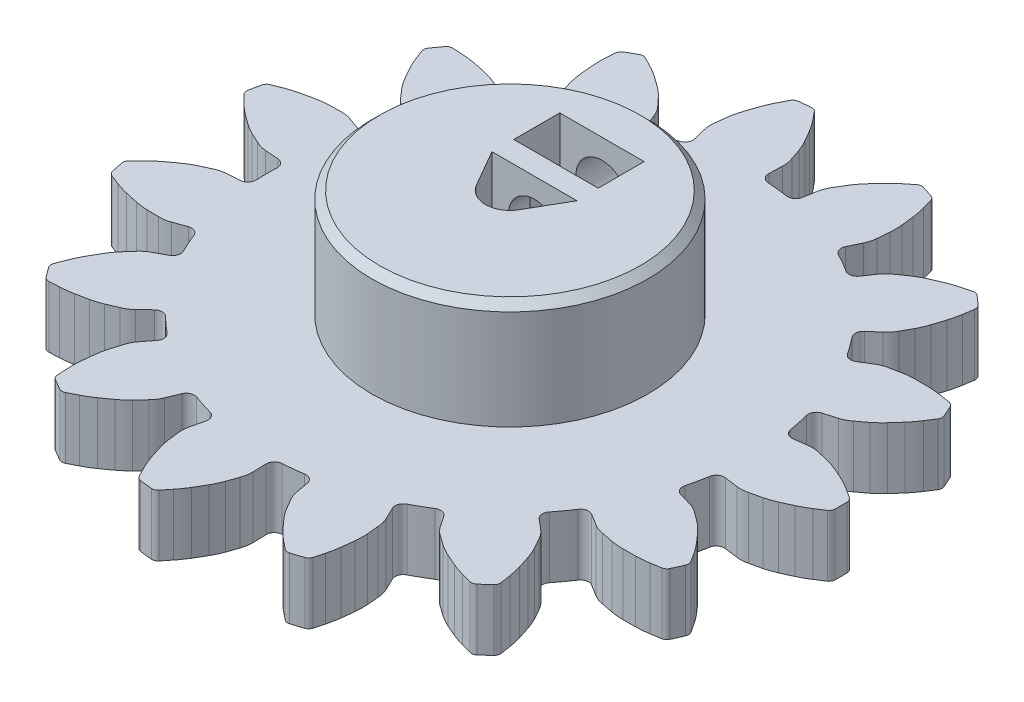
from build123d import *

# Parameters (mm, degrees)
BOSS_EXTRUDE1_DEPTH = 4
SKETCH2_R           = 9
BOSS_EXTRUDE2_DEPTH = 11
CUT_EXTRUDE1_DEPTH  = 12
SKETCH4_W           = 5.5
SKETCH4_H           = 3
CUT_EXTRUDE2_DEPTH  = 6
SKETCH5_R           = 1.7
CUT_EXTRUDE3_DEPTH  = 20.910692973
CHAMFER1_SIZE       = 0.5


with BuildPart() as part:
    # Sketch1 → Boss-Extrude1 (new body)
    with BuildSketch(Plane(origin=(0, 0, 0), x_dir=(1, 0, 0), z_dir=(0, 1, 0))):
        with BuildLine():
            Line((625.655538963, 307.001959395), (626.515572218, 307.118507349))
            ThreePointArc((626.515572218, 307.118507349), (626.884116246, 307.132277804), (627.248364172, 307.074504331))
            ThreePointArc((627.248364172, 307.074504331), (627.621576046, 306.989699865), (627.994774348, 306.904835695))
            ThreePointArc((627.994774348, 306.904835695), (628.37582392, 306.789350553), (628.746632196, 306.644309812))
            ThreePointArc((628.746632196, 306.644309812), (629.123956149, 306.476519105), (629.498991111, 306.303672745))
            ThreePointArc((629.498991111, 306.303672745), (629.880277829, 306.108693095), (630.247578808, 305.888496327))
            ThreePointArc((630.247578808, 305.888496327), (630.531649894, 305.70400205), (630.814613461, 305.517813601))
            ThreePointArc((630.814613461, 305.517813601), (630.944063756, 305.377153086), (630.993224545, 305.192420913))
            ThreePointArc((630.993224545, 305.192420913), (630.995899495, 304.99621856), (630.99679117, 304.8))
            ThreePointArc((630.99679117, 304.8), (630.995899495, 304.60378144), (630.993224545, 304.407579087))
            ThreePointArc((630.993224545, 304.407579087), (630.944063756, 304.222846914), (630.814613461, 304.082186399))
            ThreePointArc((630.814613461, 304.082186399), (630.531649894, 303.89599795), (630.247578808, 303.711503673))
            ThreePointArc((630.247578808, 303.711503673), (629.880277829, 303.491306905), (629.498991111, 303.296327255))
            ThreePointArc((629.498991111, 303.296327255), (629.123956149, 303.123480895), (628.746632196, 302.955690188))
            ThreePointArc((628.746632196, 302.955690188), (628.37582392, 302.810649447), (627.994774348, 302.695164305))
            ThreePointArc((627.994774348, 302.695164305), (627.621576046, 302.610300135), (627.248364172, 302.525495669))
            ThreePointArc((627.248364172, 302.525495669), (626.884116246, 302.467722196), (626.515572218, 302.481492651))
            Line((626.515572218, 302.481492651), (625.655538963, 302.598040605))
            ThreePointArc((625.655538963, 302.598040605), (625.269561163, 302.499520027), (625.060781309, 302.160261809))
            ThreePointArc((625.060781309, 302.160261809), (625.001333924, 301.829164882), (624.934884332, 301.499401908))
            ThreePointArc((624.934884332, 301.499401908), (624.86146237, 301.171120958), (624.781101006, 300.844469434))
            ThreePointArc((624.781101006, 300.844469434), (624.833842145, 300.449623213), (625.146378481, 300.202628872))
            Line((625.146378481, 300.202628872), (625.979462278, 299.959293687))
            ThreePointArc((625.979462278, 299.959293687), (626.32174495, 299.821973262), (626.6310034, 299.62104159))
            ThreePointArc((626.6310034, 299.62104159), (626.937456328, 299.39176991), (627.243872574, 299.162449209))
            ThreePointArc((627.243872574, 299.162449209), (627.545006641, 298.901961459), (627.824763473, 298.618638835))
            ThreePointArc((627.824763473, 298.618638835), (628.101219427, 298.311882918), (628.373527964, 298.00143945))
            ThreePointArc((628.373527964, 298.00143945), (628.642545346, 297.668233396), (628.888529393, 297.317678872))
            ThreePointArc((628.888529393, 297.317678872), (629.073000659, 297.033592844), (629.255771077, 296.74840958))
            ThreePointArc((629.255771077, 296.74840958), (629.316818019, 296.567257628), (629.286591291, 296.378500896))
            ThreePointArc((629.286591291, 296.378500896), (629.209232294, 296.198173127), (629.130237601, 296.018555876))
            ThreePointArc((629.130237601, 296.018555876), (629.049613737, 295.839663978), (628.967367361, 295.661512211))
            ThreePointArc((628.967367361, 295.661512211), (628.847319402, 295.512746467), (628.671848888, 295.436898871))
            ThreePointArc((628.671848888, 295.436898871), (628.337619141, 295.381898911), (628.003066709, 295.328897122))
            ThreePointArc((628.003066709, 295.328897122), (627.577958474, 295.277132132), (627.150330355, 295.254092638))
            ThreePointArc((627.150330355, 295.254092638), (626.737415921, 295.248730093), (626.324466709, 295.248917132))
            ThreePointArc((626.324466709, 295.248917132), (625.926723109, 295.267237135), (625.531644964, 295.316723033))
            ThreePointArc((625.531644964, 295.316723033), (625.156193983, 295.39098918), (624.780754887, 295.46531539))
            ThreePointArc((624.780754887, 295.46531539), (624.42449926, 295.560689675), (624.093418486, 295.723169972))
            Line((624.093418486, 295.723169972), (623.355143336, 296.179448865))
            ThreePointArc((623.355143336, 296.179448865), (622.962463141, 296.246437153), (622.633744505, 296.021427766))
            ThreePointArc((622.633744505, 296.021427766), (622.444767364, 295.743135102), (622.249935956, 295.46890912))
            ThreePointArc((622.249935956, 295.46890912), (622.049337764, 295.198872951), (621.843062861, 294.933147846))
            ThreePointArc((621.843062861, 294.933147846), (621.730645862, 294.550986121), (621.915700364, 294.198225583))
            Line((621.915700364, 294.198225583), (622.577786946, 293.637082123))
            ThreePointArc((622.577786946, 293.637082123), (622.834624477, 293.372414768), (623.035419856, 293.063067807))
            ThreePointArc((623.035419856, 293.063067807), (623.222125343, 292.728972071), (623.40877738, 292.39484647))
            ThreePointArc((623.40877738, 292.39484647), (623.577927126, 292.034396809), (623.718260016, 291.661781359))
            ThreePointArc((623.718260016, 291.661781359), (623.846046225, 291.269101118), (623.968543719, 290.874739037))
            ThreePointArc((623.968543719, 290.874739037), (624.078776214, 290.460920934), (624.160910453, 290.040622715))
            ThreePointArc((624.160910453, 290.040622715), (624.213885143, 289.706065991), (624.264859744, 289.371198689))
            ThreePointArc((624.264859744, 289.371198689), (624.246947764, 289.180878118), (624.142559994, 289.020734581))
            ThreePointArc((624.142559994, 289.020734581), (623.998543122, 288.887461706), (623.853320961, 288.755503218))
            ThreePointArc((623.853320961, 288.755503218), (623.706905507, 288.624870017), (623.559308852, 288.495572894))
            ThreePointArc((623.559308852, 288.495572894), (623.389131105, 288.408496529), (623.197980818, 288.41057659))
            ThreePointArc((623.197980818, 288.41057659), (622.870276251, 288.496275111), (622.543089627, 288.5839303))
            ThreePointArc((622.543089627, 288.5839303), (622.133679211, 288.709547726), (621.73365048, 288.862432126))
            ThreePointArc((621.73365048, 288.862432126), (621.354253231, 289.025480628), (620.97708143, 289.193613073))
            ThreePointArc((620.97708143, 289.193613073), (620.621175987, 289.372126125), (620.28038187, 289.5780265))
            ThreePointArc((620.28038187, 289.5780265), (619.967597095, 289.798581674), (619.654847608, 290.019186883))
            ThreePointArc((619.654847608, 290.019186883), (619.368184114, 290.251217846), (619.131813467, 290.534313666))
            Line((619.131813467, 290.534313666), (618.642950902, 291.251428732))
            ThreePointArc((618.642950902, 291.251428732), (618.311466286, 291.472343003), (617.919647307, 291.400488613))
            ThreePointArc((617.919647307, 291.400488613), (617.633816273, 291.223119543), (617.34429117, 291.051846715))
            ThreePointArc((617.34429117, 291.051846715), (617.051201999, 290.886747034), (616.754680361, 290.727894634))
            ThreePointArc((616.754680361, 290.727894634), (616.496543145, 290.424496639), (616.522118207, 290.026965405))
            Line((616.522118207, 290.026965405), (616.898726789, 289.245040471))
            ThreePointArc((616.898726789, 289.245040471), (617.025709638, 288.898789576), (617.083322599, 288.534516227))
            ThreePointArc((617.083322599, 288.534516227), (617.117997571, 288.153364622), (617.152611567, 287.772207474))
            ThreePointArc((617.152611567, 287.772207474), (617.160529464, 287.374120924), (617.137173581, 286.976641243))
            ThreePointArc((617.137173581, 286.976641243), (617.094194649, 286.565934659), (617.045700169, 286.155842752))
            ThreePointArc((617.045700169, 286.155842752), (616.978087577, 285.732965508), (616.882170251, 285.315596975))
            ThreePointArc((616.882170251, 285.315596975), (616.79448856, 284.988417452), (616.704853373, 284.661767712))
            ThreePointArc((616.704853373, 284.661767712), (616.611079615, 284.495186676), (616.450580397, 284.391346607))
            ThreePointArc((616.450580397, 284.391346607), (616.264807476, 284.328172716), (616.078468079, 284.266689813))
            ThreePointArc((616.078468079, 284.266689813), (615.891577596, 284.206902977), (615.704151465, 284.148817145))
            ThreePointArc((615.704151465, 284.148817145), (615.513269208, 284.138486452), (615.339490768, 284.218134509))
            ThreePointArc((615.339490768, 284.218134509), (615.074974479, 284.429713459), (614.811727202, 284.642869248))
            ThreePointArc((614.811727202, 284.642869248), (614.488805387, 284.924148695), (614.185544644, 285.226521888))
            ThreePointArc((614.185544644, 285.226521888), (613.90526581, 285.529788869), (613.629087851, 285.836795093))
            ThreePointArc((613.629087851, 285.836795093), (613.37655985, 286.144634666), (613.14897616, 286.471347474))
            ThreePointArc((613.14897616, 286.471347474), (612.95294092, 286.80005568), (612.756958269, 287.128795243))
            ThreePointArc((612.756958269, 287.128795243), (612.589453632, 287.457362622), (612.488663744, 287.812124126))
            Line((612.488663744, 287.812124126), (612.333742544, 288.666079656))
            ThreePointArc((612.333742544, 288.666079656), (612.120770207, 289.002721825), (611.733599945, 289.09644671))
            ThreePointArc((611.733599945, 289.09644671), (611.400337802, 289.050669956), (611.066180525, 289.011964911))
            ThreePointArc((611.066180525, 289.011964911), (610.731278154, 288.980348954), (610.395781066, 288.95583628))
            ThreePointArc((610.395781066, 288.95583628), (610.036557903, 288.783662284), (609.898231365, 288.410097116))
            Line((609.898231365, 288.410097116), (609.924242902, 287.542592635))
            ThreePointArc((609.924242902, 287.542592635), (609.89941458, 287.174628125), (609.80388332, 286.818414559))
            ThreePointArc((609.80388332, 286.818414559), (609.680532158, 286.45611166), (609.557123038, 286.093828498))
            ThreePointArc((609.557123038, 286.093828498), (609.40244001, 285.72693784), (609.219433798, 285.373321776))
            ThreePointArc((609.219433798, 285.373321776), (609.013121172, 285.015603748), (608.802019855, 284.660690632))
            ThreePointArc((608.802019855, 284.660690632), (608.568253009, 284.301873565), (608.310869095, 283.959601529))
            ThreePointArc((608.310869095, 283.959601529), (608.097691984, 283.696371518), (607.882945747, 283.434420047))
            ThreePointArc((607.882945747, 283.434420047), (607.729524545, 283.320381922), (607.540665652, 283.290800211))
            ThreePointArc((607.540665652, 283.290800211), (607.345258508, 283.308648645), (607.150021648, 283.328272279))
            ThreePointArc((607.150021648, 283.328272279), (606.954971199, 283.349669494), (606.760123272, 283.372838521))
            ThreePointArc((606.760123272, 283.372838521), (606.581541783, 283.441039772), (606.455183062, 283.584483952))
            ThreePointArc((606.455183062, 283.584483952), (606.299592319, 283.885359408), (606.145802235, 284.187159225))
            ThreePointArc((606.145802235, 284.187159225), (605.965205135, 284.575464921), (605.811148918, 284.975043834))
            ThreePointArc((605.811148918, 284.975043834), (605.678451257, 285.36609168), (605.551020818, 285.758887517))
            ThreePointArc((605.551020818, 285.758887517), (605.445534644, 286.142825352), (605.370512669, 286.533858979))
            ThreePointArc((605.370512669, 286.533858979), (605.325123238, 286.913883583), (605.279794604, 287.293915444))
            ThreePointArc((605.279794604, 287.293915444), (605.260411896, 287.662206954), (605.312630256, 288.027292655))
            Line((605.312630256, 288.027292655), (605.518437702, 288.87043198))
            ThreePointArc((605.518437702, 288.87043198), (605.460802497, 289.264593557), (605.145226208, 289.507691833))
            ThreePointArc((605.145226208, 289.507691833), (604.822157008, 289.601422613), (604.501146384, 289.701977804))
            ThreePointArc((604.501146384, 289.701977804), (604.182338476, 289.809312256), (603.865876433, 289.923377773))
            ThreePointArc((603.865876433, 289.923377773), (603.467680271, 289.912198225), (603.189370048, 289.627191934))
            Line((603.189370048, 289.627191934), (602.86028691, 288.82410731))
            ThreePointArc((602.86028691, 288.82410731), (602.687940459, 288.498053592), (602.455783201, 288.211492371))
            ThreePointArc((602.455783201, 288.211492371), (602.195734442, 287.930683641), (601.935640764, 287.649916515))
            ThreePointArc((601.935640764, 287.649916515), (601.645102911, 287.377660477), (601.334089807, 287.12905146))
            ThreePointArc((601.334089807, 287.12905146), (601.000116815, 286.886174686), (600.662909996, 286.647808061))
            ThreePointArc((600.662909996, 286.647808061), (600.303409306, 286.415093902), (599.929062822, 286.207100307))
            ThreePointArc((599.929062822, 286.207100307), (599.627250549, 286.053334669), (599.324524838, 285.901375256))
            ThreePointArc((599.324524838, 285.901375256), (599.137984112, 285.85959827), (598.953420962, 285.909389864))
            ThreePointArc((598.953420962, 285.909389864), (598.782167265, 286.005174465), (598.61179117, 286.102511532))
            ThreePointArc((598.61179117, 286.102511532), (598.44230675, 286.201393025), (598.273728004, 286.301810777))
            ThreePointArc((598.273728004, 286.301810777), (598.138325643, 286.436751356), (598.081235211, 286.619188856))
            ThreePointArc((598.081235211, 286.619188856), (598.061473068, 286.957336719), (598.04373188, 287.295596634))
            ThreePointArc((598.04373188, 287.295596634), (598.036686375, 287.723786997), (598.058472404, 288.151480806))
            ThreePointArc((598.058472404, 288.151480806), (598.096300546, 288.56269379), (598.139651507, 288.973361272))
            ThreePointArc((598.139651507, 288.973361272), (598.199446679, 289.36701103), (598.289958399, 289.75475221))
            ThreePointArc((598.289958399, 289.75475221), (598.403063022, 290.120383505), (598.516226138, 290.485996702))
            ThreePointArc((598.516226138, 290.485996702), (598.648316805, 290.830331396), (598.844514383, 291.14261466))
            Line((598.844514383, 291.14261466), (599.375464499, 291.82915133))
            ThreePointArc((599.375464499, 291.82915133), (599.483132076, 292.212678198), (599.293715768, 292.563115964))
            ThreePointArc((599.293715768, 292.563115964), (599.03670111, 292.780147374), (598.784342794, 293.002575896))
            ThreePointArc((598.784342794, 293.002575896), (598.536754132, 293.230301655), (598.294046296, 293.463222399))
            ThreePointArc((598.294046296, 293.463222399), (597.925728869, 293.614970344), (597.555557328, 293.467803108))
            Line((597.555557328, 293.467803108), (596.928280977, 292.867998968))
            ThreePointArc((596.928280977, 292.867998968), (596.638216665, 292.640233692), (596.309575507, 292.472873854))
            ThreePointArc((596.309575507, 292.472873854), (595.957793944, 292.322113673), (595.605988268, 292.171409771))
            ThreePointArc((595.605988268, 292.171409771), (595.229832225, 292.040863894), (594.84458922, 291.940248682))
            ThreePointArc((594.84458922, 291.940248682), (594.440702826, 291.854208762), (594.035696628, 291.773604384))
            ThreePointArc((594.035696628, 291.773604384), (593.61262303, 291.707231525), (593.186041883, 291.669480353))
            ThreePointArc((593.186041883, 291.669480353), (592.847780532, 291.651766564), (592.509419372, 291.636074372))
            ThreePointArc((592.509419372, 291.636074372), (592.322013708, 291.673782145), (592.173658947, 291.794337626))
            ThreePointArc((592.173658947, 291.794337626), (592.056170018, 291.951496366), (591.940114262, 292.109716403))
            ThreePointArc((591.940114262, 292.109716403), (591.825501266, 292.268984666), (591.712340497, 292.429288))
            ThreePointArc((591.712340497, 292.429288), (591.643529564, 292.607635455), (591.665578876, 292.797521175))
            ThreePointArc((591.665578876, 292.797521175), (591.785062386, 293.114472607), (591.906437706, 293.430704407))
            ThreePointArc((591.906437706, 293.430704407), (592.074162028, 293.824741433), (592.2680233, 294.206597994))
            ThreePointArc((592.2680233, 294.206597994), (592.469836417, 294.566873655), (592.676473003, 294.924404644))
            ThreePointArc((592.676473003, 294.924404644), (592.891210392, 295.259700705), (593.131605508, 295.577105466))
            ThreePointArc((593.131605508, 295.577105466), (593.383647369, 295.86512248), (593.635735303, 296.153099169))
            ThreePointArc((593.635735303, 296.153099169), (593.89645967, 296.41393845), (594.202712122, 296.619422663))
            Line((594.202712122, 296.619422663), (594.96699881, 297.030648251))
            ThreePointArc((594.96699881, 297.030648251), (595.221352467, 297.337225131), (595.190847939, 297.734408514))
            ThreePointArc((595.190847939, 297.734408514), (595.044327993, 298.037213851), (594.90425703, 298.343055791))
            ThreePointArc((594.90425703, 298.343055791), (594.770697944, 298.651797005), (594.643710704, 298.963298864))
            ThreePointArc((594.643710704, 298.963298864), (594.368957441, 299.251735703), (593.970930603, 299.267854073))
            Line((593.970930603, 299.267854073), (593.15392282, 298.975042004))
            ThreePointArc((593.15392282, 298.975042004), (592.796295402, 298.884947854), (592.427995386, 298.865727436))
            ThreePointArc((592.427995386, 298.865727436), (592.045307247, 298.871083609), (591.66261997, 298.876501004))
            ThreePointArc((591.66261997, 298.876501004), (591.265886535, 298.910237857), (590.873025643, 298.975013734))
            ThreePointArc((590.873025643, 298.975013734), (590.469061475, 299.060687751), (590.066285148, 299.15178285))
            ThreePointArc((590.066285148, 299.15178285), (589.65279191, 299.263227761), (589.247735856, 299.402246533))
            ThreePointArc((589.247735856, 299.402246533), (588.931513889, 299.523647468), (588.616022998, 299.64693582))
            ThreePointArc((588.616022998, 299.64693582), (588.460156538, 299.757608335), (588.373662052, 299.928082564))
            ThreePointArc((588.373662052, 299.928082564), (588.330252793, 300.119441271), (588.28858447, 300.311186595))
            ThreePointArc((588.28858447, 300.311186595), (588.248660527, 300.503302699), (588.210484261, 300.695773713))
            ThreePointArc((588.210484261, 300.695773713), (588.22016279, 300.886690148), (588.31753932, 301.051191122))
            ThreePointArc((588.31753932, 301.051191122), (588.555608699, 301.292142341), (588.795113633, 301.531666675))
            ThreePointArc((588.795113633, 301.531666675), (589.108606722, 301.823417782), (589.441022862, 302.093410626))
            ThreePointArc((589.441022862, 302.093410626), (589.771925631, 302.340454031), (590.1061185, 302.58302817))
            ThreePointArc((590.1061185, 302.58302817), (590.43866806, 302.801994799), (590.787380074, 302.994180973))
            ThreePointArc((590.787380074, 302.994180973), (591.134778845, 303.154782948), (591.482203303, 303.315329344))
            ThreePointArc((591.482203303, 303.315329344), (591.826479758, 303.447571731), (592.189833254, 303.510726805))
            Line((592.189833254, 303.510726805), (593.055304401, 303.575536672))
            ThreePointArc((593.055304401, 303.575536672), (593.41236408, 303.752153636), (593.546045843, 304.12740602))
            ThreePointArc((593.546045843, 304.12740602), (593.535355238, 304.463627492), (593.53179117, 304.8))
            ThreePointArc((593.53179117, 304.8), (593.535355238, 305.136372508), (593.546045843, 305.47259398))
            ThreePointArc((593.546045843, 305.47259398), (593.41236408, 305.847846364), (593.055304401, 306.024463328))
            Line((593.055304401, 306.024463328), (592.189833254, 306.089273195))
            ThreePointArc((592.189833254, 306.089273195), (591.826479758, 306.152428269), (591.482203303, 306.284670656))
            ThreePointArc((591.482203303, 306.284670656), (591.134778845, 306.445217052), (590.787380074, 306.605819027))
            ThreePointArc((590.787380074, 306.605819027), (590.43866806, 306.798005201), (590.1061185, 307.01697183))
            ThreePointArc((590.1061185, 307.01697183), (589.771925631, 307.259545969), (589.441022862, 307.506589374))
            ThreePointArc((589.441022862, 307.506589374), (589.108606722, 307.776582218), (588.795113633, 308.068333325))
            ThreePointArc((588.795113633, 308.068333325), (588.555608699, 308.307857659), (588.31753932, 308.548808878))
            ThreePointArc((588.31753932, 308.548808878), (588.22016279, 308.713309852), (588.210484261, 308.904226287))
            ThreePointArc((588.210484261, 308.904226287), (588.248660527, 309.096697301), (588.28858447, 309.288813405))
            ThreePointArc((588.28858447, 309.288813405), (588.330252793, 309.480558729), (588.373662052, 309.671917436))
            ThreePointArc((588.373662052, 309.671917436), (588.460156538, 309.842391665), (588.616022998, 309.95306418))
            ThreePointArc((588.616022998, 309.95306418), (588.931513889, 310.076352532), (589.247735856, 310.197753467))
            ThreePointArc((589.247735856, 310.197753467), (589.65279191, 310.336772239), (590.066285148, 310.44821715))
            ThreePointArc((590.066285148, 310.44821715), (590.469061475, 310.539312249), (590.873025643, 310.624986266))
            ThreePointArc((590.873025643, 310.624986266), (591.265886535, 310.689762143), (591.66261997, 310.723498996))
            ThreePointArc((591.66261997, 310.723498996), (592.045307247, 310.728916391), (592.427995386, 310.734272564))
            ThreePointArc((592.427995386, 310.734272564), (592.796295402, 310.715052146), (593.15392282, 310.624957996))
            Line((593.15392282, 310.624957996), (593.970930603, 310.332145927))
            ThreePointArc((593.970930603, 310.332145927), (594.368957441, 310.348264297), (594.643710704, 310.636701136))
            ThreePointArc((594.643710704, 310.636701136), (594.770697944, 310.948202995), (594.90425703, 311.256944209))
            ThreePointArc((594.90425703, 311.256944209), (595.044327993, 311.562786149), (595.190847939, 311.865591486))
            ThreePointArc((595.190847939, 311.865591486), (595.221352467, 312.262774869), (594.96699881, 312.569351749))
            Line((594.96699881, 312.569351749), (594.202712122, 312.980577337))
            ThreePointArc((594.202712122, 312.980577337), (593.89645967, 313.18606155), (593.635735303, 313.446900831))
            ThreePointArc((593.635735303, 313.446900831), (593.383647369, 313.73487752), (593.131605508, 314.022894534))
            ThreePointArc((593.131605508, 314.022894534), (592.891210392, 314.340299295), (592.676473003, 314.675595356))
            ThreePointArc((592.676473003, 314.675595356), (592.469836417, 315.033126345), (592.2680233, 315.393402006))
            ThreePointArc((592.2680233, 315.393402006), (592.074162028, 315.775258567), (591.906437706, 316.169295593))
            ThreePointArc((591.906437706, 316.169295593), (591.785062386, 316.485527393), (591.665578876, 316.802478825))
            ThreePointArc((591.665578876, 316.802478825), (591.643529564, 316.992364545), (591.712340497, 317.170712))
            ThreePointArc((591.712340497, 317.170712), (591.825501266, 317.331015334), (591.940114262, 317.490283597))
            ThreePointArc((591.940114262, 317.490283597), (592.056170018, 317.648503634), (592.173658947, 317.805662374))
            ThreePointArc((592.173658947, 317.805662374), (592.322013708, 317.926217855), (592.509419372, 317.963925628))
            ThreePointArc((592.509419372, 317.963925628), (592.847780532, 317.948233436), (593.186041883, 317.930519647))
            ThreePointArc((593.186041883, 317.930519647), (593.61262303, 317.892768475), (594.035696628, 317.826395616))
            ThreePointArc((594.035696628, 317.826395616), (594.440702826, 317.745791238), (594.84458922, 317.659751318))
            ThreePointArc((594.84458922, 317.659751318), (595.229832225, 317.559136106), (595.605988268, 317.428590229))
            ThreePointArc((595.605988268, 317.428590229), (595.957793944, 317.277886327), (596.309575507, 317.127126146))
            ThreePointArc((596.309575507, 317.127126146), (596.638216665, 316.959766308), (596.928280977, 316.732001032))
            Line((596.928280977, 316.732001032), (597.555557328, 316.132196892))
            ThreePointArc((597.555557328, 316.132196892), (597.925728869, 315.985029656), (598.294046296, 316.136777601))
            ThreePointArc((598.294046296, 316.136777601), (598.536754132, 316.369698345), (598.784342794, 316.597424104))
            ThreePointArc((598.784342794, 316.597424104), (599.03670111, 316.819852626), (599.293715768, 317.036884036))
            ThreePointArc((599.293715768, 317.036884036), (599.483132076, 317.387321802), (599.375464499, 317.77084867))
            Line((599.375464499, 317.77084867), (598.844514383, 318.45738534))
            ThreePointArc((598.844514383, 318.45738534), (598.648316805, 318.769668604), (598.516226138, 319.114003298))
            ThreePointArc((598.516226138, 319.114003298), (598.403063023, 319.479616495), (598.289958399, 319.84524779))
            ThreePointArc((598.289958399, 319.84524779), (598.199446679, 320.23298897), (598.139651507, 320.626638728))
            ThreePointArc((598.139651507, 320.626638728), (598.096300546, 321.03730621), (598.058472404, 321.448519194))
            ThreePointArc((598.058472404, 321.448519194), (598.036686375, 321.876213003), (598.04373188, 322.304403366))
            ThreePointArc((598.04373188, 322.304403366), (598.061473068, 322.642663281), (598.081235211, 322.980811144))
            ThreePointArc((598.081235211, 322.980811144), (598.138325643, 323.163248644), (598.273728004, 323.298189223))
            ThreePointArc((598.273728004, 323.298189223), (598.44230675, 323.398606975), (598.61179117, 323.497488468))
            ThreePointArc((598.61179117, 323.497488468), (598.782167265, 323.594825535), (598.953420962, 323.690610136))
            ThreePointArc((598.953420962, 323.690610136), (599.137984112, 323.74040173), (599.324524838, 323.698624744))
            ThreePointArc((599.324524838, 323.698624744), (599.627250549, 323.546665331), (599.929062822, 323.392899693))
            ThreePointArc((599.929062822, 323.392899693), (600.303409306, 323.184906098), (600.662909996, 322.952191939))
            ThreePointArc((600.662909996, 322.952191939), (601.000116815, 322.713825314), (601.334089807, 322.47094854))
            ThreePointArc((601.334089807, 322.47094854), (601.645102911, 322.222339523), (601.935640764, 321.950083485))
            ThreePointArc((601.935640764, 321.950083485), (602.195734442, 321.669316359), (602.455783201, 321.388507629))
            ThreePointArc((602.455783201, 321.388507629), (602.687940459, 321.101946408), (602.86028691, 320.77589269))
            Line((602.86028691, 320.77589269), (603.189370048, 319.972808066))
            ThreePointArc((603.189370048, 319.972808066), (603.467680271, 319.687801775), (603.865876433, 319.676622227))
            ThreePointArc((603.865876433, 319.676622227), (604.182338476, 319.790687744), (604.501146384, 319.898022196))
            ThreePointArc((604.501146384, 319.898022196), (604.822157008, 319.998577387), (605.145226208, 320.092308167))
            ThreePointArc((605.145226208, 320.092308167), (605.460802497, 320.335406443), (605.518437702, 320.72956802))
            Line((605.518437702, 320.72956802), (605.312630256, 321.572707345))
            ThreePointArc((605.312630256, 321.572707345), (605.260411896, 321.937793046), (605.279794604, 322.306084556))
            ThreePointArc((605.279794604, 322.306084556), (605.325123238, 322.686116417), (605.370512669, 323.066141021))
            ThreePointArc((605.370512669, 323.066141021), (605.445534644, 323.457174648), (605.551020818, 323.841112483))
            ThreePointArc((605.551020818, 323.841112483), (605.678451257, 324.23390832), (605.811148918, 324.624956166))
            ThreePointArc((605.811148918, 324.624956166), (605.965205135, 325.024535079), (606.145802235, 325.412840775))
            ThreePointArc((606.145802235, 325.412840775), (606.299592319, 325.714640592), (606.455183062, 326.015516048))
            ThreePointArc((606.455183062, 326.015516048), (606.581541783, 326.158960228), (606.760123272, 326.227161479))
            ThreePointArc((606.760123272, 326.227161479), (606.954971199, 326.250330506), (607.150021648, 326.271727721))
            ThreePointArc((607.150021648, 326.271727721), (607.345258508, 326.291351355), (607.540665652, 326.309199789))
            ThreePointArc((607.540665652, 326.309199789), (607.729524545, 326.279618078), (607.882945747, 326.165579953))
            ThreePointArc((607.882945747, 326.165579953), (608.097691984, 325.903628482), (608.310869095, 325.640398471))
            ThreePointArc((608.310869095, 325.640398471), (608.568253009, 325.298126435), (608.802019855, 324.939309368))
            ThreePointArc((608.802019855, 324.939309368), (609.013121172, 324.584396252), (609.219433798, 324.226678224))
            ThreePointArc((609.219433798, 324.226678224), (609.40244001, 323.87306216), (609.557123038, 323.506171502))
            ThreePointArc((609.557123038, 323.506171502), (609.680532158, 323.14388834), (609.80388332, 322.781585441))
            ThreePointArc((609.80388332, 322.781585441), (609.89941458, 322.425371875), (609.924242902, 322.057407365))
            Line((609.924242902, 322.057407365), (609.898231365, 321.189902884))
            ThreePointArc((609.898231365, 321.189902884), (610.036557903, 320.816337716), (610.395781066, 320.64416372))
            ThreePointArc((610.395781066, 320.64416372), (610.731278154, 320.619651046), (611.066180525, 320.588035089))
            ThreePointArc((611.066180525, 320.588035089), (611.400337802, 320.549330044), (611.733599945, 320.50355329))
            ThreePointArc((611.733599945, 320.50355329), (612.120770207, 320.597278175), (612.333742544, 320.933920344))
            Line((612.333742544, 320.933920344), (612.488663744, 321.787875874))
            ThreePointArc((612.488663744, 321.787875874), (612.589453632, 322.142637378), (612.756958269, 322.471204757))
            ThreePointArc((612.756958269, 322.471204757), (612.95294092, 322.79994432), (613.14897616, 323.128652526))
            ThreePointArc((613.14897616, 323.128652526), (613.37655985, 323.455365334), (613.629087851, 323.763204907))
            ThreePointArc((613.629087851, 323.763204907), (613.90526581, 324.070211131), (614.185544644, 324.373478112))
            ThreePointArc((614.185544644, 324.373478112), (614.488805387, 324.675851305), (614.811727202, 324.957130752))
            ThreePointArc((614.811727202, 324.957130752), (615.074974479, 325.170286541), (615.339490768, 325.381865491))
            ThreePointArc((615.339490768, 325.381865491), (615.513269208, 325.461513548), (615.704151465, 325.451182855))
            ThreePointArc((615.704151465, 325.451182855), (615.891577596, 325.393097023), (616.078468079, 325.333310187))
            ThreePointArc((616.078468079, 325.333310187), (616.264807476, 325.271827284), (616.450580397, 325.208653393))
            ThreePointArc((616.450580397, 325.208653393), (616.611079615, 325.104813324), (616.704853373, 324.938232288))
            ThreePointArc((616.704853373, 324.938232288), (616.79448856, 324.611582548), (616.882170251, 324.284403025))
            ThreePointArc((616.882170251, 324.284403025), (616.978087577, 323.867034492), (617.045700169, 323.444157248))
            ThreePointArc((617.045700169, 323.444157248), (617.094194649, 323.034065341), (617.137173581, 322.623358757))
            ThreePointArc((617.137173581, 322.623358757), (617.160529464, 322.225879076), (617.152611567, 321.827792526))
            ThreePointArc((617.152611567, 321.827792526), (617.117997571, 321.446635378), (617.083322599, 321.065483773))
            ThreePointArc((617.083322599, 321.065483773), (617.025709638, 320.701210424), (616.898726789, 320.354959529))
            Line((616.898726789, 320.354959529), (616.522118207, 319.573034595))
            ThreePointArc((616.522118207, 319.573034595), (616.496543145, 319.175503361), (616.754680361, 318.872105366))
            ThreePointArc((616.754680361, 318.872105366), (617.051201999, 318.713252966), (617.34429117, 318.548153285))
            ThreePointArc((617.34429117, 318.548153285), (617.633816273, 318.376880457), (617.919647307, 318.199511387))
            ThreePointArc((617.919647307, 318.199511387), (618.311466286, 318.127656997), (618.642950902, 318.348571268))
            Line((618.642950902, 318.348571268), (619.131813467, 319.065686334))
            ThreePointArc((619.131813467, 319.065686334), (619.368184114, 319.348782154), (619.654847608, 319.580813117))
            ThreePointArc((619.654847608, 319.580813117), (619.967597095, 319.801418326), (620.28038187, 320.0219735))
            ThreePointArc((620.28038187, 320.0219735), (620.621175986, 320.227873875), (620.97708143, 320.406386927))
            ThreePointArc((620.97708143, 320.406386927), (621.354253231, 320.574519372), (621.73365048, 320.737567874))
            ThreePointArc((621.73365048, 320.737567874), (622.133679211, 320.890452274), (622.543089627, 321.0160697))
            ThreePointArc((622.543089627, 321.0160697), (622.870276251, 321.103724889), (623.197980818, 321.18942341))
            ThreePointArc((623.197980818, 321.18942341), (623.389131105, 321.191503471), (623.559308852, 321.104427106))
            ThreePointArc((623.559308852, 321.104427106), (623.706905507, 320.975129983), (623.853320961, 320.844496782))
            ThreePointArc((623.853320961, 320.844496782), (623.998543122, 320.712538294), (624.142559994, 320.579265419))
            ThreePointArc((624.142559994, 320.579265419), (624.246947764, 320.419121882), (624.264859744, 320.228801311))
            ThreePointArc((624.264859744, 320.228801311), (624.213885143, 319.893934009), (624.160910453, 319.559377285))
            ThreePointArc((624.160910453, 319.559377285), (624.078776214, 319.139079066), (623.968543719, 318.725260963))
            ThreePointArc((623.968543719, 318.725260963), (623.846046225, 318.330898882), (623.718260016, 317.938218641))
            ThreePointArc((623.718260016, 317.938218641), (623.577927126, 317.565603191), (623.40877738, 317.20515353))
            ThreePointArc((623.40877738, 317.20515353), (623.222125343, 316.871027929), (623.035419856, 316.536932193))
            ThreePointArc((623.035419856, 316.536932193), (622.834624477, 316.227585232), (622.577786946, 315.962917877))
            Line((622.577786946, 315.962917877), (621.915700364, 315.401774417))
            ThreePointArc((621.915700364, 315.401774417), (621.730645862, 315.049013879), (621.843062861, 314.666852154))
            ThreePointArc((621.843062861, 314.666852154), (622.049337764, 314.401127049), (622.249935956, 314.13109088))
            ThreePointArc((622.249935956, 314.13109088), (622.444767364, 313.856864898), (622.633744505, 313.578572234))
            ThreePointArc((622.633744505, 313.578572234), (622.962463141, 313.353562847), (623.355143336, 313.420551135))
            Line((623.355143336, 313.420551135), (624.093418486, 313.876830028))
            ThreePointArc((624.093418486, 313.876830028), (624.42449926, 314.039310325), (624.780754887, 314.13468461))
            ThreePointArc((624.780754887, 314.13468461), (625.156193983, 314.20901082), (625.531644964, 314.283276967))
            ThreePointArc((625.531644964, 314.283276967), (625.926723109, 314.332762865), (626.324466709, 314.351082868))
            ThreePointArc((626.324466709, 314.351082868), (626.737415921, 314.351269907), (627.150330355, 314.345907362))
            ThreePointArc((627.150330355, 314.345907362), (627.577958474, 314.322867868), (628.003066709, 314.271102878))
            ThreePointArc((628.003066709, 314.271102878), (628.337619141, 314.218101089), (628.671848888, 314.163101129))
            ThreePointArc((628.671848888, 314.163101129), (628.847319402, 314.087253533), (628.967367361, 313.938487789))
            ThreePointArc((628.967367361, 313.938487789), (629.049613737, 313.760336022), (629.130237601, 313.581444124))
            ThreePointArc((629.130237601, 313.581444124), (629.209232294, 313.401826873), (629.286591291, 313.221499104))
            ThreePointArc((629.286591291, 313.221499104), (629.316818019, 313.032742372), (629.255771077, 312.85159042))
            ThreePointArc((629.255771077, 312.85159042), (629.073000659, 312.566407156), (628.888529393, 312.282321128))
            ThreePointArc((628.888529393, 312.282321128), (628.642545346, 311.931766604), (628.373527964, 311.59856055))
            ThreePointArc((628.373527964, 311.59856055), (628.101219427, 311.288117082), (627.824763473, 310.981361165))
            ThreePointArc((627.824763473, 310.981361165), (627.545006641, 310.698038541), (627.243872574, 310.437550791))
            ThreePointArc((627.243872574, 310.437550791), (626.937456328, 310.20823009), (626.6310034, 309.97895841))
            ThreePointArc((626.6310034, 309.97895841), (626.32174495, 309.778026738), (625.979462278, 309.640706313))
            Line((625.979462278, 309.640706313), (625.146378481, 309.397371128))
            ThreePointArc((625.146378481, 309.397371128), (624.833842145, 309.150376787), (624.781101006, 308.755530566))
            ThreePointArc((624.781101006, 308.755530566), (624.86146237, 308.428879042), (624.934884332, 308.100598092))
            ThreePointArc((624.934884332, 308.100598092), (625.001333924, 307.770835118), (625.060781309, 307.439738191))
            ThreePointArc((625.060781309, 307.439738191), (625.269561163, 307.100479973), (625.655538963, 307.001959395))
        make_face()
    extrude(amount=BOSS_EXTRUDE1_DEPTH)

    # Sketch2 → Boss-Extrude2 (add)
    with BuildSketch(Plane(origin=(0, 0, 0), x_dir=(1, 0, 0), z_dir=(0, 1, 0))):
        with Locations((609.40679117, 304.8)):
            Circle(SKETCH2_R)
    extrude(amount=BOSS_EXTRUDE2_DEPTH)

    # Sketch3 → Cut-Extrude1 (cut, through all)
    with BuildSketch(Plane(origin=(0, 0, 0), x_dir=(1, 0, 0), z_dir=(0, 1, 0))):
        with BuildLine():
            Line((612.178072462, 306.4), (606.635509878, 306.4))
            Line((606.635509878, 306.4), (608.021150524, 304))
            ThreePointArc((608.021150524, 304), (609.40679117, 303.2), (610.792431816, 304))
            Line((610.792431816, 304), (612.178072462, 306.4))
        make_face()
    extrude(amount=CUT_EXTRUDE1_DEPTH, mode=Mode.SUBTRACT)

    # Sketch4 → Cut-Extrude2 (cut)
    with BuildSketch(Plane(origin=(0, 11, 0), x_dir=(1, 0, 0), z_dir=(0, 1, 0))):
        with Locations((609.40679117, 309.3)):
            Rectangle(SKETCH4_W, SKETCH4_H)
    extrude(amount=-CUT_EXTRUDE2_DEPTH, mode=Mode.SUBTRACT)

    # Sketch5 → Cut-Extrude3 (cut, through all)
    with BuildSketch(Plane.XY.offset(-306.4)):
        with Locations((609.40679117, 8)):
            Circle(SKETCH5_R)
    extrude(amount=-CUT_EXTRUDE3_DEPTH, mode=Mode.SUBTRACT)

    # Chamfer1
    chamfer1_edges = [part.edges().sort_by_distance(p)[0] for p in [
        (600.40679117, 11, -304.8),
    ]]
    chamfer(chamfer1_edges, length=CHAMFER1_SIZE)


solid = part.part
